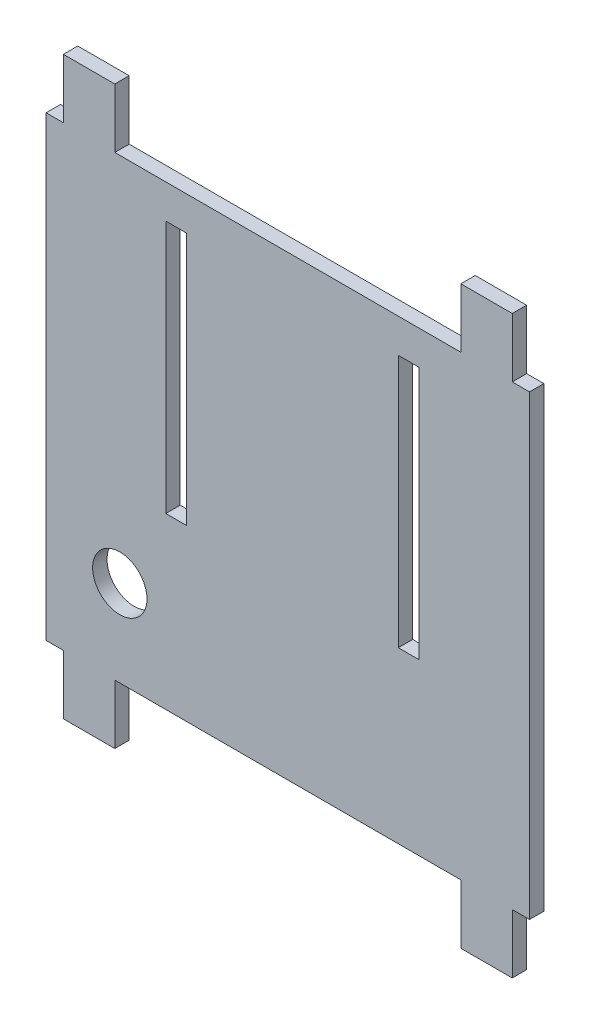
from build123d import *

# Parameters (mm, degrees)
SKETCH1_W           = 106.68
SKETCH1_H           = 127
BOSS_EXTRUDE1_DEPTH = 3.175
SKETCH2_W           = 4.572
SKETCH2_H           = 55.88
CUT_EXTRUDE1_DEPTH  = 3.175
SKETCH3_W           = 3.81
SKETCH3_H           = 13.0800094
SKETCH3_W_2         = 76.36002
CUT_EXTRUDE2_DEPTH  = 3.175
SKETCH4_R           = 5.999999938
CUT_EXTRUDE3_DEPTH  = 3.175


with BuildPart() as part:
    # Sketch1 → Boss-Extrude1 (new body)
    with BuildSketch(Plane.XY):
        with Locations((15.161716065, 15.987172316)):
            Rectangle(SKETCH1_W, SKETCH1_H)
    extrude(amount=BOSS_EXTRUDE1_DEPTH)

    # Sketch2 → Cut-Extrude1 (cut)
    with BuildSketch(Plane.XY.offset(3.175)):
        with Locations((-9.476283935, 30.973172316)):
            Rectangle(SKETCH2_W, SKETCH2_H)
        with Locations((41.831716065, 30.973172316)):
            Rectangle(SKETCH2_W, SKETCH2_H)
    extrude(amount=-CUT_EXTRUDE1_DEPTH, mode=Mode.SUBTRACT)

    # Sketch3 → Cut-Extrude2 (cut)
    with BuildSketch(Plane.XY.offset(3.175)):
        with Locations((-36.273283935, 72.947167616)):
            Rectangle(SKETCH3_W, SKETCH3_H)
        with Locations((15.161716065, 72.947167616)):
            Rectangle(SKETCH3_W_2, SKETCH3_H)
        with Locations((-36.273283935, -40.972822984)):
            Rectangle(SKETCH3_W, SKETCH3_H)
        with Locations((66.596716065, 72.947167616)):
            Rectangle(SKETCH3_W, SKETCH3_H)
        with Locations((15.161716065, -40.972822984)):
            Rectangle(SKETCH3_W_2, SKETCH3_H)
        with Locations((66.596716065, -40.972822984)):
            Rectangle(SKETCH3_W, SKETCH3_H)
    extrude(amount=-CUT_EXTRUDE2_DEPTH, mode=Mode.SUBTRACT)

    # Sketch4 → Cut-Extrude3 (cut)
    with BuildSketch(Plane.XY.offset(3.175)):
        with Locations((-21.909583935, -15.382818284)):
            Circle(SKETCH4_R)
    extrude(amount=-CUT_EXTRUDE3_DEPTH, mode=Mode.SUBTRACT)


solid = part.part
